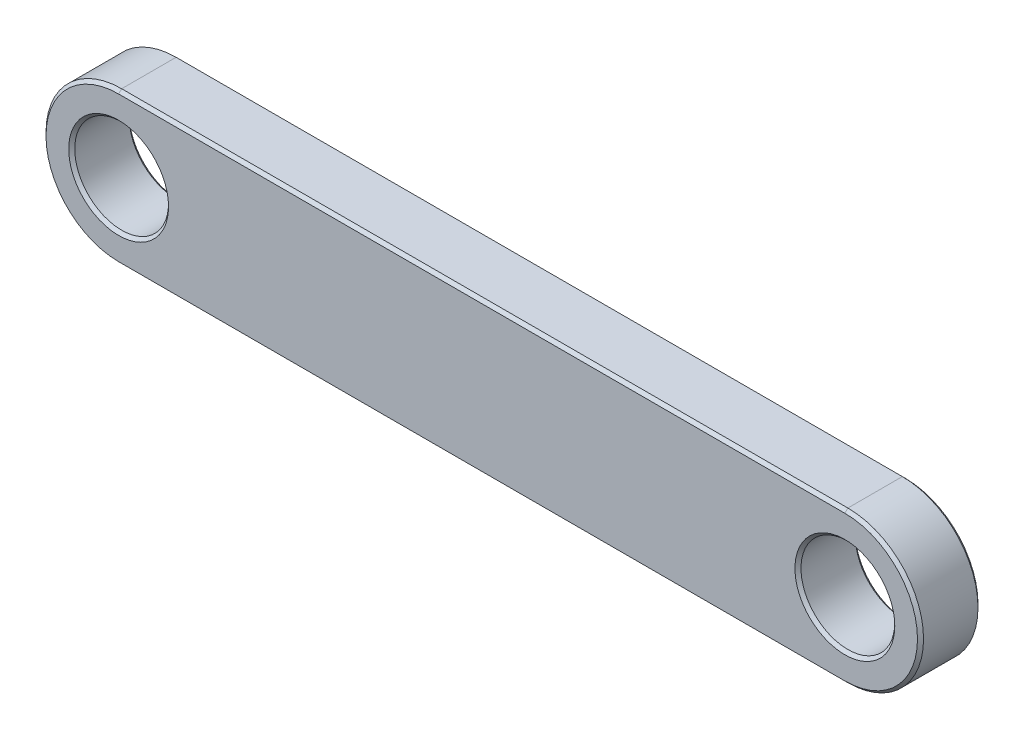
from build123d import *

# Parameters (mm, degrees)
BOSS_EXTRUDE1_DEPTH = 2
SKETCH2_R           = 1.55
CUT_EXTRUDE1_DEPTH  = 2
CHAMFER1_SIZE       = 0.1


with BuildPart() as part:
    # Sketch1 → Boss-Extrude1 (new body)
    with BuildSketch(Plane.XY):
        with BuildLine():
            Line((-12, 2.5), (12, 2.5))
            ThreePointArc((12, 2.5), (14.5, 0), (12, -2.5))
            Line((12, -2.5), (-12, -2.5))
            ThreePointArc((-12, -2.5), (-14.5, 0), (-12, 2.5))
        make_face()
    extrude(amount=BOSS_EXTRUDE1_DEPTH)

    # Sketch2 → Cut-Extrude1 (cut)
    with BuildSketch(Plane.XY.offset(2)):
        with Locations((-12, 0)):
            Circle(SKETCH2_R)
        with Locations((12, 0)):
            Circle(SKETCH2_R)
    extrude(amount=-CUT_EXTRUDE1_DEPTH, mode=Mode.SUBTRACT)

    # Chamfer1
    chamfer1_edges = [part.edges().sort_by_distance(p)[0] for p in [
        (14.5, 0, 2),
        (0, 2.5, 2),
        (-13.55, 0, 0),
        (-13.55, 0, 2),
        (10.45, 0, 0),
        (10.45, 0, 2),
        (-14.5, 0, 2),
        (0, 2.5, 0),
        (14.5, 0, 0),
        (0, -2.5, 0),
        (-14.5, 0, 0),
        (0, -2.5, 2),
    ]]
    chamfer(chamfer1_edges, length=CHAMFER1_SIZE)


solid = part.part
